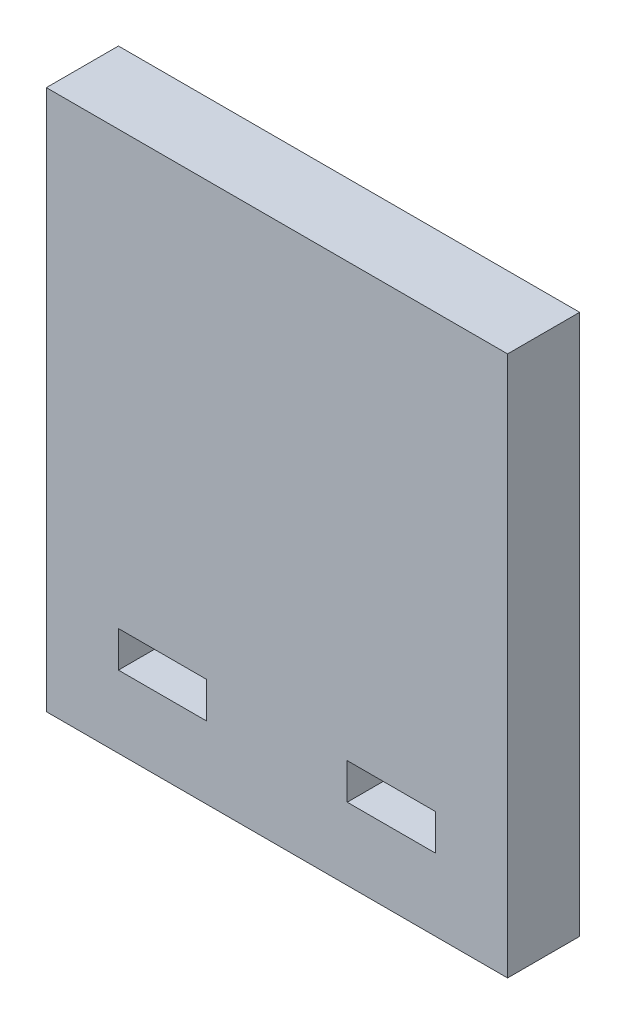
from build123d import *

# Parameters (mm, degrees)
SKETCH2_W           = 128
SKETCH2_H           = 150
SKETCH2_W_2         = 24.5
SKETCH2_H_2         = 10
BOSS_EXTRUDE1_DEPTH = 20


with BuildPart() as part:
    # Sketch2 → Boss-Extrude1 (new body)
    with BuildSketch(Plane.XY):
        Rectangle(SKETCH2_W, SKETCH2_H)
        with Locations((-31.75, -50)):
            Rectangle(SKETCH2_W_2, SKETCH2_H_2, mode=Mode.SUBTRACT)
        with Locations((31.75, -50)):
            Rectangle(SKETCH2_W_2, SKETCH2_H_2, mode=Mode.SUBTRACT)
    extrude(amount=BOSS_EXTRUDE1_DEPTH)


solid = part.part
